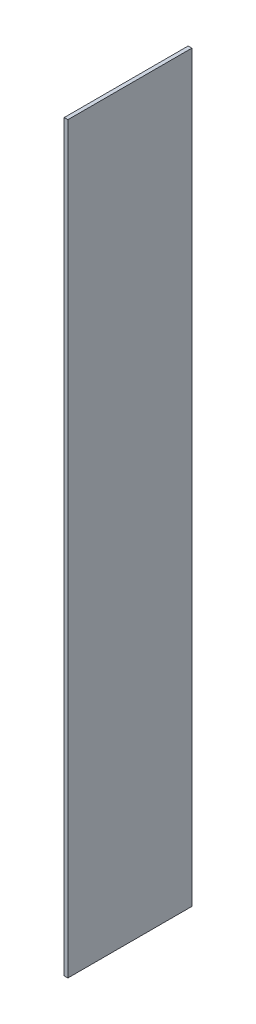
from build123d import *

# Parameters (mm, degrees)
SKETCH1_W           = 1.5
SKETCH1_H           = 50
BOSS_EXTRUDE1_DEPTH = 150


with BuildPart() as part:
    # Sketch1 → Boss-Extrude1 (new body, symmetric)
    with BuildSketch(Plane(origin=(0, 0, 0), x_dir=(1, 0, 0), z_dir=(0, 1, 0))):
        Rectangle(SKETCH1_W, SKETCH1_H)
    extrude(amount=BOSS_EXTRUDE1_DEPTH, both=True)


solid = part.part
